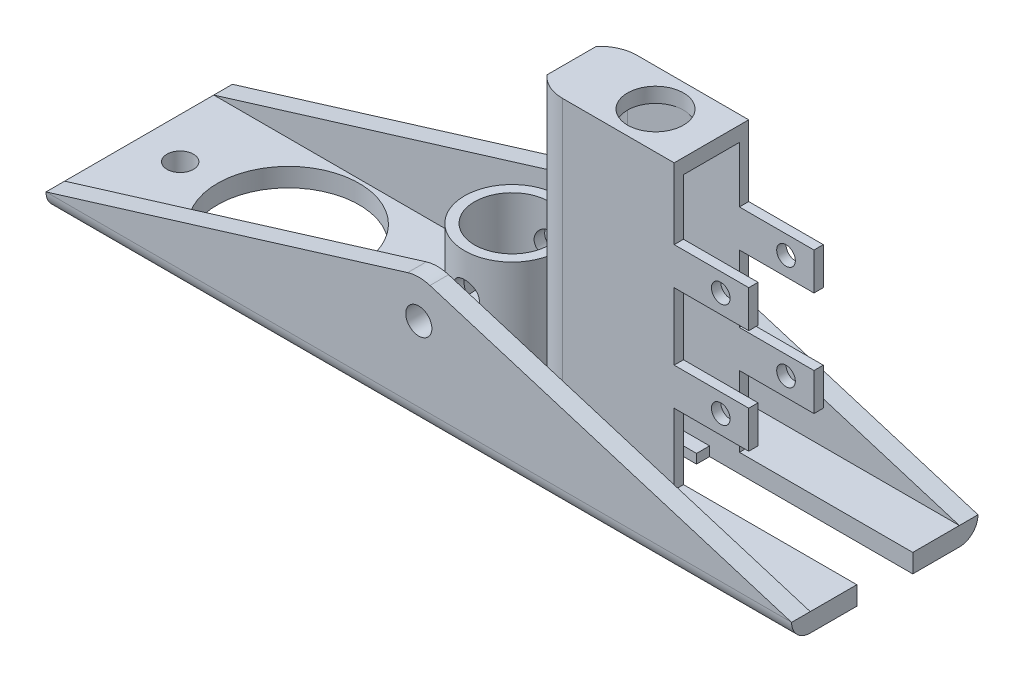
from build123d import *

# Parameters (mm, degrees)
SKETCH2_W                       = 200
SKETCH2_H                       = 50
SKETCH2_R                       = 19
SKETCH2_R_2                     = 3.55
BOSS_EXTRUDE1_DEPTH             = 5
BOSS_EXTRUDE3_REACH             = 27
BOSS_EXTRUDE3_DIRECTION_2_REACH = 27
CUT_EXTRUDE2_DEPTH              = 20
CUT_EXTRUDE2_DEPTH_BACK         = 20
SKETCH8_R                       = 12.75
SKETCH8_R_2                     = 10.05
BOSS_EXTRUDE4_DEPTH             = 30.2
FILLET1_R                       = 5
SKETCH9_R                       = 3.5
CUT_EXTRUDE3_DEPTH              = 51
SKETCH13_R                      = 2
CUT_EXTRUDE5_DEPTH              = 2.5
CUT_EXTRUDE6_DEPTH              = 6
BOSS_EXTRUDE7_DEPTH             = 72
SKETCH17_R                      = 7.5
BOSS_EXTRUDE8_DEPTH             = 4
SKETCH18_R                      = 10.05
BOSS_EXTRUDE9_DEPTH             = 9.5
SKETCH19_W                      = 2.5
SKETCH19_H                      = 10
BOSS_EXTRUDE10_DEPTH            = 20
SKETCH20_R                      = 2.5
CUT_EXTRUDE7_DEPTH              = 36
SKETCH21_W                      = 3.5
SKETCH21_H                      = 5
CUT_EXTRUDE8_DEPTH              = 54.5


with BuildPart() as part:
    # Sketch2 → Boss-Extrude1 (new body)
    with BuildSketch(Plane(origin=(0, 0, 0), x_dir=(1, 0, 0), z_dir=(0, 1, 0))):
        Rectangle(SKETCH2_W, SKETCH2_H)
        with Locations((-60, 0)):
            Circle(SKETCH2_R, mode=Mode.SUBTRACT)
        with Locations((-31, 0)):
            Circle(SKETCH2_R_2, mode=Mode.SUBTRACT)
        with Locations((-89, 0)):
            Circle(SKETCH2_R_2, mode=Mode.SUBTRACT)
    extrude(amount=BOSS_EXTRUDE1_DEPTH)

    # Boss-Extrude3: up to this face of the body (flat: up to its plane)
    boss_extrude3_end = Plane(part.part.faces().sort_by_distance((0, 2.5, -25))[0])
    # Sketch6 → Boss-Extrude3 (add, up to the picked face)
    with BuildSketch(Plane.XY, mode=Mode.PRIVATE) as boss_extrude3_sk1:
        with BuildLine():
            Line((-100, 5), (-2.990738274, 34.75169137))
            ThreePointArc((-2.990738274, 34.75169137), (0, 35.2), (2.990738274, 34.75169137))
            Line((2.990738274, 34.75169137), (100, 5))
            Line((100, 5), (-100, 5))
        make_face()
    boss_extrude3_tool1 = split(extrude(boss_extrude3_sk1.sketch, amount=-BOSS_EXTRUDE3_REACH, mode=Mode.PRIVATE), bisect_by=boss_extrude3_end, keep=Keep.BOTH, mode=Mode.PRIVATE)
    add(boss_extrude3_tool1.solids().sort_by_distance((0, 15.216769, 0))[0])

    # Boss-Extrude3 direction 2: up to this face of the body (flat: up to its plane)
    boss_extrude3_direction_2_end = Plane(part.part.faces().sort_by_distance((0, 2.5, 25))[0])
    # Sketch6 → Boss-Extrude3 direction 2 (add, up to the picked face)
    with BuildSketch(Plane.XY, mode=Mode.PRIVATE) as boss_extrude3_direction_2_sk1:
        with BuildLine():
            Line((-100, 5), (-2.990738274, 34.75169137))
            ThreePointArc((-2.990738274, 34.75169137), (0, 35.2), (2.990738274, 34.75169137))
            Line((2.990738274, 34.75169137), (100, 5))
            Line((100, 5), (-100, 5))
        make_face()
    boss_extrude3_direction_2_tool1 = split(extrude(boss_extrude3_direction_2_sk1.sketch, amount=BOSS_EXTRUDE3_DIRECTION_2_REACH, mode=Mode.PRIVATE), bisect_by=boss_extrude3_direction_2_end, keep=Keep.BOTH, mode=Mode.PRIVATE)
    add(boss_extrude3_direction_2_tool1.solids().sort_by_distance((0, 15.216769, 0))[0])

    # Sketch7 → Cut-Extrude2 (cut, two sides)
    with BuildSketch(Plane.XY) as cut_extrude2_sk:
        with BuildLine():
            Line((2.990738274, 34.75169137), (100, 5))
            Line((100, 5), (-100, 5))
            Line((-100, 5), (-2.990738274, 34.75169137))
            ThreePointArc((-2.990738274, 34.75169137), (0, 35.2), (2.990738274, 34.75169137))
        make_face()
    extrude(amount=CUT_EXTRUDE2_DEPTH, mode=Mode.SUBTRACT)
    extrude(cut_extrude2_sk.sketch, amount=-CUT_EXTRUDE2_DEPTH_BACK, mode=Mode.SUBTRACT)

    # Sketch8 → Boss-Extrude4 (add)
    with BuildSketch(Plane(origin=(0, 5, 0), x_dir=(1, 0, 0), z_dir=(0, 1, 0))):
        Circle(SKETCH8_R)
        Circle(SKETCH8_R_2, mode=Mode.SUBTRACT)
    extrude(amount=BOSS_EXTRUDE4_DEPTH)

    # Fillet1
    fillet1_edges = [part.edges().sort_by_distance(p)[0] for p in [
        (0, 0, -25),
        (0, 0, 25),
    ]]
    fillet(fillet1_edges, radius=FILLET1_R)

    # Sketch9 → Cut-Extrude3 (cut, through all)
    with BuildSketch(Plane.XY.offset(25)):
        with Locations((0, 25)):
            Circle(SKETCH9_R)
    extrude(amount=-CUT_EXTRUDE3_DEPTH, mode=Mode.SUBTRACT)

    # Sketch13 → Cut-Extrude5 (cut)
    with BuildSketch(Plane(origin=(0, 5, 0), x_dir=(1, 0, 0), z_dir=(0, 1, 0))):
        with BuildLine():
            Line((23.5, 7.5), (53.5, 7.5))
            ThreePointArc((53.5, 7.5), (61, 0), (53.5, -7.5))
            Line((53.5, -7.5), (23.5, -7.5))
            ThreePointArc((23.5, -7.5), (16, 0), (23.5, 7.5))
        make_face()
        with Locations((31.5, 0)):
            Circle(SKETCH13_R, mode=Mode.SUBTRACT)
        with Locations((24.5, 0)):
            Circle(SKETCH13_R, mode=Mode.SUBTRACT)
        with Locations((38.5, 0)):
            Circle(SKETCH13_R, mode=Mode.SUBTRACT)
        with Locations((45.5, 0)):
            Circle(SKETCH13_R, mode=Mode.SUBTRACT)
        with Locations((52.5, 0)):
            Circle(SKETCH13_R, mode=Mode.SUBTRACT)
    extrude(amount=-CUT_EXTRUDE5_DEPTH, mode=Mode.SUBTRACT)

    # Sketch15 → Cut-Extrude6 (cut, through all)
    with BuildSketch(Plane(origin=(0, 5, 0), x_dir=(1, 0, 0), z_dir=(0, 1, 0))):
        with BuildLine():
            Line((23.5, 4), (53.5, 4))
            Line((53.5, 4), (100, 4))
            Line((100, 4), (100, -4))
            Line((100, -4), (53.5, -4))
            Line((53.5, -4), (23.5, -4))
            ThreePointArc((23.5, -4), (19.5, 0), (23.5, 4))
        make_face()
    extrude(amount=-CUT_EXTRUDE6_DEPTH, mode=Mode.SUBTRACT)

    # Sketch16 → Boss-Extrude7 (add)
    with BuildSketch(Plane(origin=(0, 5, 0), x_dir=(1, 0, 0), z_dir=(0, 1, 0))):
        with BuildLine():
            Line((16, -4), (16, -6.614378278))
            ThreePointArc((16, -6.614378278), (19.385621722, -9.114378278), (23.5, -10))
            Line((23.5, -10), (53.5, -10))
            Line((53.5, -10), (53.5, -7.5))
            Line((53.5, -7.5), (23.5, -7.5))
            ThreePointArc((23.5, -7.5), (19.877155813, -6.566962768), (17.15571123, -4))
            Line((17.15571123, -4), (16, -4))
        make_face()
        with BuildLine():
            Line((53.5, 10), (23.5, 10))
            ThreePointArc((23.5, 10), (19.385621722, 9.114378278), (16, 6.614378278))
            Line((16, 6.614378278), (16, 4))
            Line((16, 4), (17.15571123, 4))
            ThreePointArc((17.15571123, 4), (19.877155813, 6.566962768), (23.5, 7.5))
            Line((23.5, 7.5), (53.5, 7.5))
            Line((53.5, 7.5), (53.5, 10))
        make_face()
    extrude(amount=BOSS_EXTRUDE7_DEPTH)

    # Sketch17 → Boss-Extrude8 (add)
    with BuildSketch(Plane(origin=(0, 77, 0), x_dir=(1, 0, 0), z_dir=(0, 1, 0))):
        with BuildLine():
            Line((23.5, -10), (53.5, -10))
            Line((53.5, -10), (53.5, 10))
            Line((53.5, 10), (23.5, 10))
            ThreePointArc((23.5, 10), (19.385621722, 9.114378278), (16, 6.614378278))
            Line((16, 6.614378278), (16, 4))
            Line((16, 4), (16, -4))
            Line((16, -4), (16, -6.614378278))
            ThreePointArc((16, -6.614378278), (19.385621722, -9.114378278), (23.5, -10))
        make_face()
        with Locations((38.5, 0)):
            Circle(SKETCH17_R, mode=Mode.SUBTRACT)
    extrude(amount=BOSS_EXTRUDE8_DEPTH)

    # Sketch18 → Boss-Extrude9 (add)
    with BuildSketch(Plane(origin=(0, 5, 0), x_dir=(1, 0, 0), z_dir=(0, 1, 0))):
        Circle(SKETCH18_R)
    extrude(amount=BOSS_EXTRUDE9_DEPTH)

    # Sketch19 → Boss-Extrude10 (add)
    with BuildSketch(Plane(origin=(53.5, 0, 0), x_dir=(0, 0, -1), z_dir=(1, 0, 0))):
        with Locations((-8.75, 57)):
            Rectangle(SKETCH19_W, SKETCH19_H)
        with Locations((8.75, 57)):
            Rectangle(SKETCH19_W, SKETCH19_H)
        with Locations((8.75, 29)):
            Rectangle(SKETCH19_W, SKETCH19_H)
        with Locations((-8.75, 29)):
            Rectangle(SKETCH19_W, SKETCH19_H)
    extrude(amount=BOSS_EXTRUDE10_DEPTH)

    # Sketch20 → Cut-Extrude7 (cut, through all)
    with BuildSketch(Plane.XY.offset(10)):
        with Locations((66, 57)):
            Circle(SKETCH20_R)
        with Locations((66, 29)):
            Circle(SKETCH20_R)
    extrude(amount=-CUT_EXTRUDE7_DEPTH, mode=Mode.SUBTRACT)

    # Sketch21 → Cut-Extrude8 (cut)
    with BuildSketch(Plane(origin=(100, 0, 0), x_dir=(0, 0, -1), z_dir=(1, 0, 0))):
        with Locations((-5.75, 2.5)):
            Rectangle(SKETCH21_W, SKETCH21_H)
        with Locations((5.75, 2.5)):
            Rectangle(SKETCH21_W, SKETCH21_H)
    extrude(amount=-CUT_EXTRUDE8_DEPTH, mode=Mode.SUBTRACT)


solid = part.part
